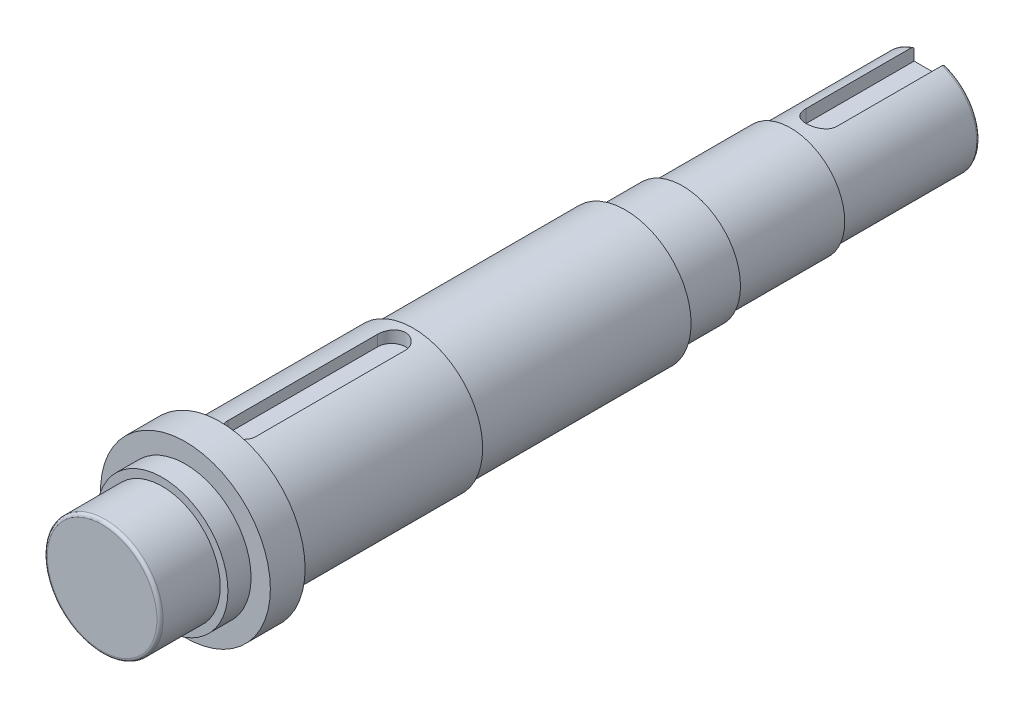
from build123d import *

# Parameters (mm, degrees)
FILLET1_R          = 2
CUT_EXTRUDE1_START = 37
CUT_EXTRUDE1_DEPTH = 10
CUT_EXTRUDE2_START = 22.5
CUT_EXTRUDE2_DEPTH = 10


with BuildPart() as part:
    # Sketch1 → Revolve1 (revolve)
    with BuildSketch(Plane(origin=(0, 0, 0), x_dir=(0, 0, -1), z_dir=(1, 0, 0))):
        Polygon((0, 0), (536, 0), (536, 32.5), (446, 32.5), (446, 35), (376, 35), (376, 37.5), (339, 37.5), (339, 42.5), (201.5, 42.5), (201.5, 45), (76.5, 45), (76.5, 55), (54, 55), (54, 42.5), (39, 42.5), (39, 37.5), (0, 37.5), align=None)
    revolve(axis=Axis((0, 0, 0), (0, 0, -1)))

    # Fillet1
    fillet1_edges = [part.edges().sort_by_distance(p)[0] for p in [
        (0, -37.5, 0),
        (0, -32.5, -536),
    ]]
    fillet(fillet1_edges, radius=FILLET1_R)

    # Sketch2 → Cut-Extrude1 (cut)
    with BuildSketch(Plane(origin=(0, 0, 0), x_dir=(1, 0, 0), z_dir=(0, 1, 0)).offset(CUT_EXTRUDE1_START)):
        with BuildLine():
            Line((9, 187.5), (9, 90.5))
            ThreePointArc((9, 90.5), (0, 81.5), (-9, 90.5))
            Line((-9, 90.5), (-9, 187.5))
            ThreePointArc((-9, 187.5), (0, 196.5), (9, 187.5))
        make_face()
    extrude(amount=CUT_EXTRUDE1_DEPTH, mode=Mode.SUBTRACT)

    # Sketch3 → Cut-Extrude2 (cut)
    with BuildSketch(Plane(origin=(0, 0, 0), x_dir=(1, 0, 0), z_dir=(0, 1, 0)).offset(CUT_EXTRUDE2_START)):
        with BuildLine():
            Line((10, 536), (10, 466))
            ThreePointArc((10, 466), (0, 456), (-10, 466))
            Line((-10, 466), (-10, 536))
            ThreePointArc((-10, 536), (0, 546), (10, 536))
        make_face()
    extrude(amount=CUT_EXTRUDE2_DEPTH, mode=Mode.SUBTRACT)


solid = part.part
